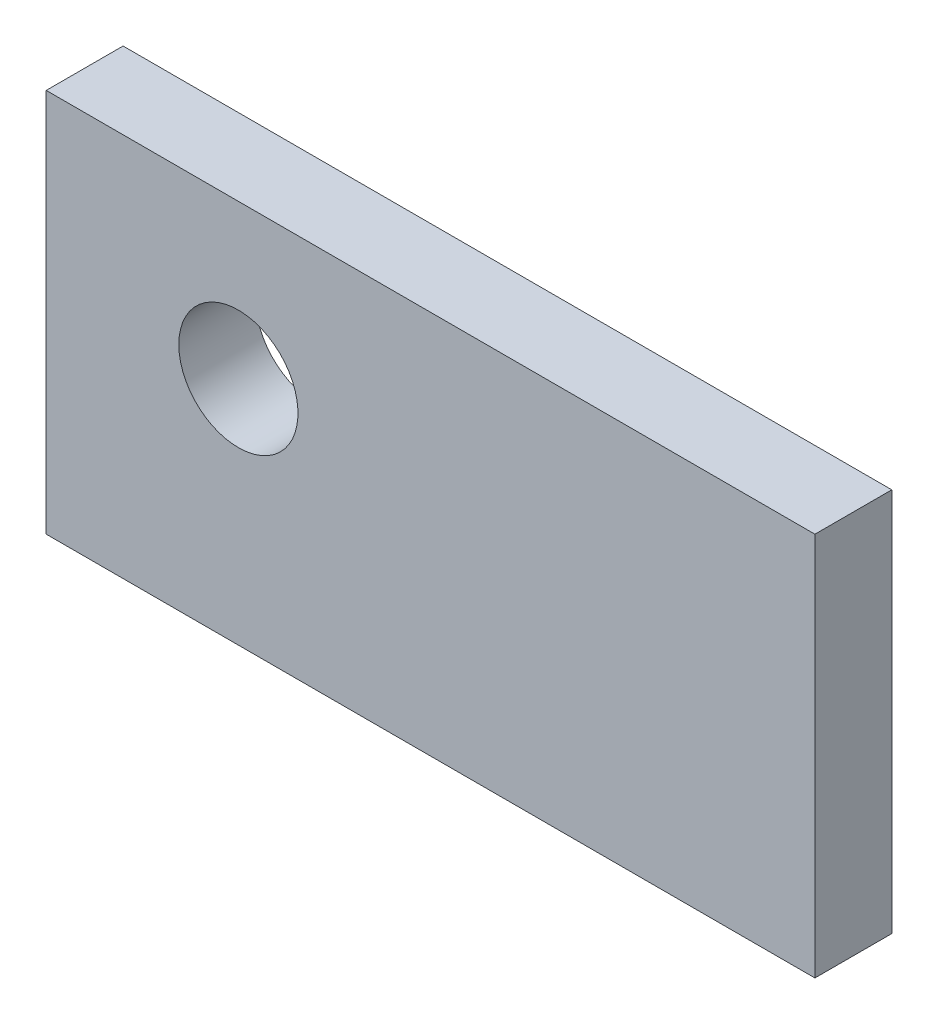
from build123d import *

# Parameters (mm, degrees)
SKETCH_1_W          = 4
SKETCH_1_H          = 20
EXTRUDE_1_DEPTH     = 40
SKETCH_2_R          = 3.1
CUT_EXTRUDE_1_DEPTH = 5


with BuildPart() as part:
    # Эскиз1 → Бобышка-Вытянуть1 (new body)
    with BuildSketch(Plane(origin=(0, 0, 0), x_dir=(0, 0, -1), z_dir=(1, 0, 0))):
        with Locations((2, 10)):
            Rectangle(SKETCH_1_W, SKETCH_1_H)
    extrude(amount=EXTRUDE_1_DEPTH)

    # Эскиз2 → Вырез-Вытянуть1 (cut, through all)
    with BuildSketch(Plane(origin=(0, 0, -4), x_dir=(-1, 0, 0), z_dir=(0, 0, -1))):
        with Locations((-10, 12)):
            Circle(SKETCH_2_R)
    extrude(amount=-CUT_EXTRUDE_1_DEPTH, mode=Mode.SUBTRACT)


solid = part.part
